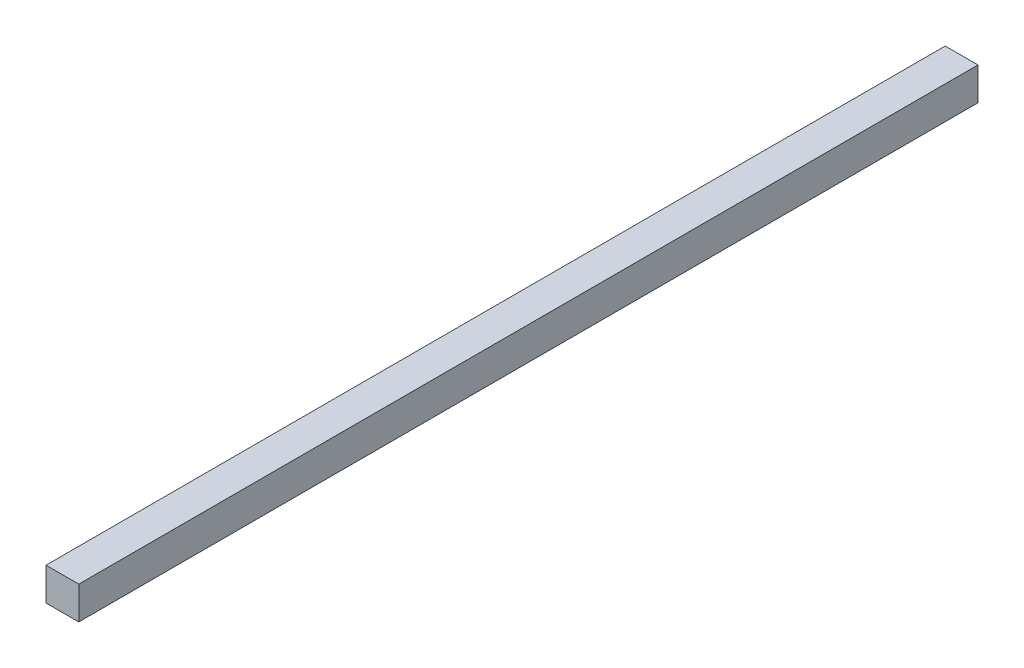
from build123d import *

# Parameters (mm, degrees)
SKETCH1_W           = 88.9
SKETCH1_H           = 2438.4
BOSS_EXTRUDE1_DEPTH = 88.9


with BuildPart() as part:
    # Sketch1 → Boss-Extrude1 (new body)
    with BuildSketch(Plane(origin=(0, 0, 0), x_dir=(1, 0, 0), z_dir=(0, 1, 0))):
        with Locations((44.45, -1219.2)):
            Rectangle(SKETCH1_W, SKETCH1_H)
    extrude(amount=BOSS_EXTRUDE1_DEPTH)


solid = part.part
